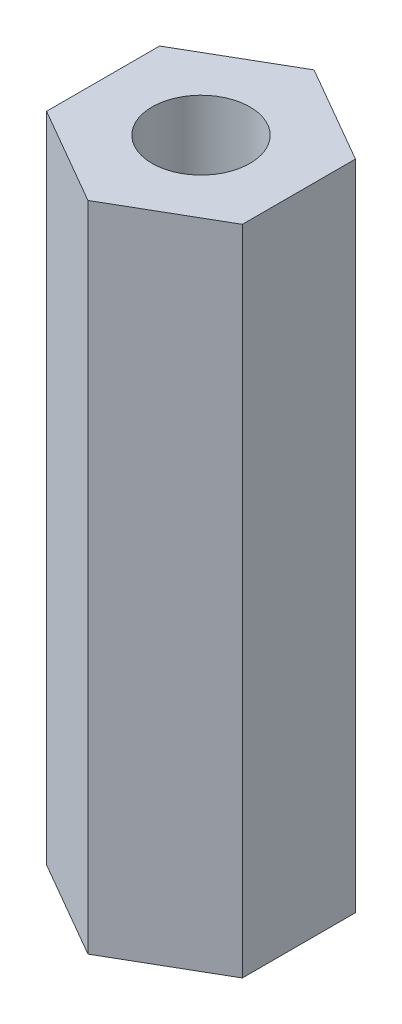
from build123d import *

# Parameters (mm, degrees)
SKETCH1_R           = 1.5
BOSS_EXTRUDE1_DEPTH = 20


with BuildPart() as part:
    # Sketch1 → Boss-Extrude1 (new body)
    with BuildSketch(Plane(origin=(0, 0, 0), x_dir=(1, 0, 0), z_dir=(0, 1, 0))):
        Polygon((0, -3.464101615), (3, -1.732050808), (3, 1.732050808), (0, 3.464101615), (-3, 1.732050808), (-3, -1.732050808), align=None)
        Circle(SKETCH1_R, mode=Mode.SUBTRACT)
    extrude(amount=BOSS_EXTRUDE1_DEPTH)


solid = part.part
